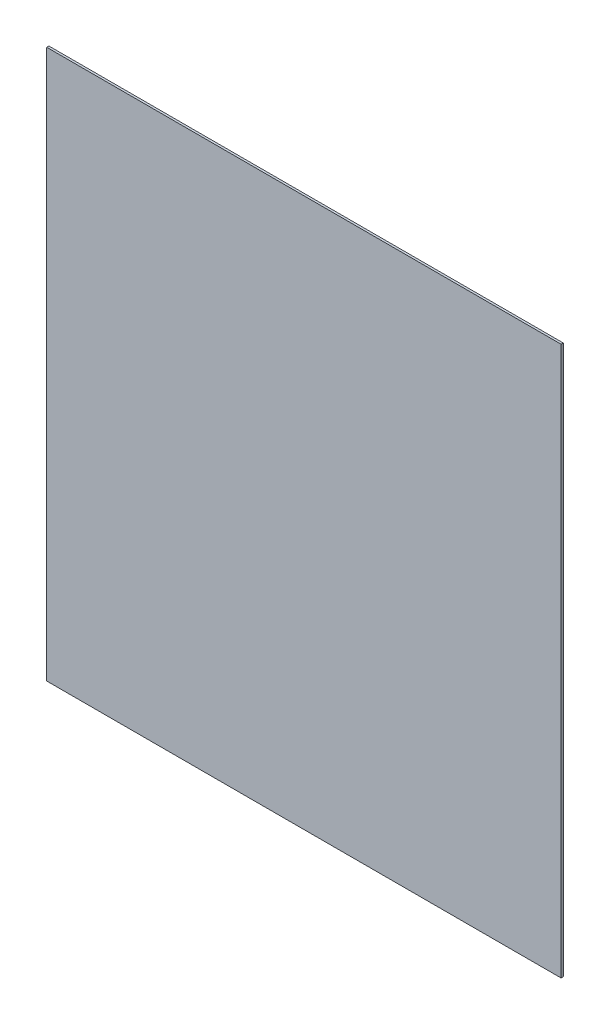
from build123d import *

# Parameters (mm, degrees)
SKETCH1_W           = 745
SKETCH1_H           = 795
BOSS_EXTRUDE1_DEPTH = 3.175


with BuildPart() as part:
    # Sketch1 → Boss-Extrude1 (new body)
    with BuildSketch(Plane.XY):
        Rectangle(SKETCH1_W, SKETCH1_H)
    extrude(amount=BOSS_EXTRUDE1_DEPTH)


solid = part.part
